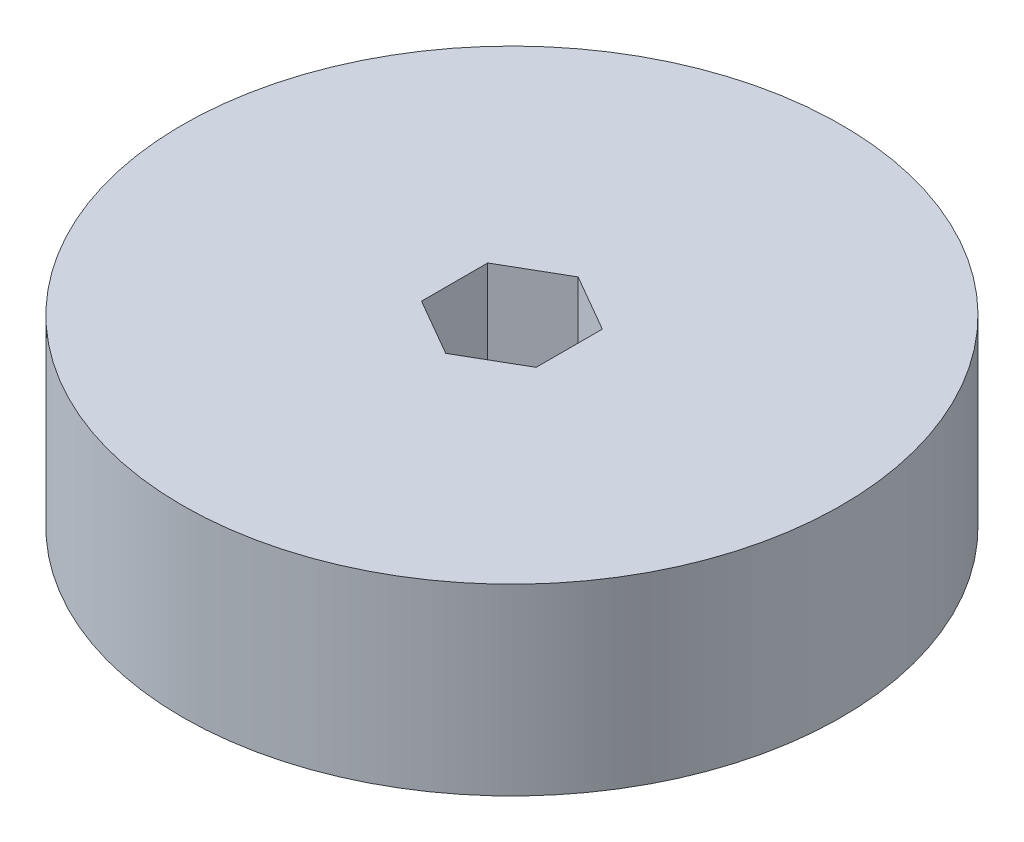
from build123d import *

# Parameters (mm, degrees)
SKETCH2_R           = 36.5125
BOSS_EXTRUDE1_DEPTH = 20.32


with BuildPart() as part:
    # Sketch2 → Boss-Extrude1 (new body)
    with BuildSketch(Plane(origin=(0, 0, 0), x_dir=(1, 0, 0), z_dir=(0, 1, 0))):
        Circle(SKETCH2_R)
        Polygon((0, 7.332348419), (-6.35, 3.666174209), (-6.35, -3.666174209), (0, -7.332348419), (6.35, -3.666174209), (6.35, 3.666174209), align=None, mode=Mode.SUBTRACT)
    extrude(amount=BOSS_EXTRUDE1_DEPTH)


solid = part.part
